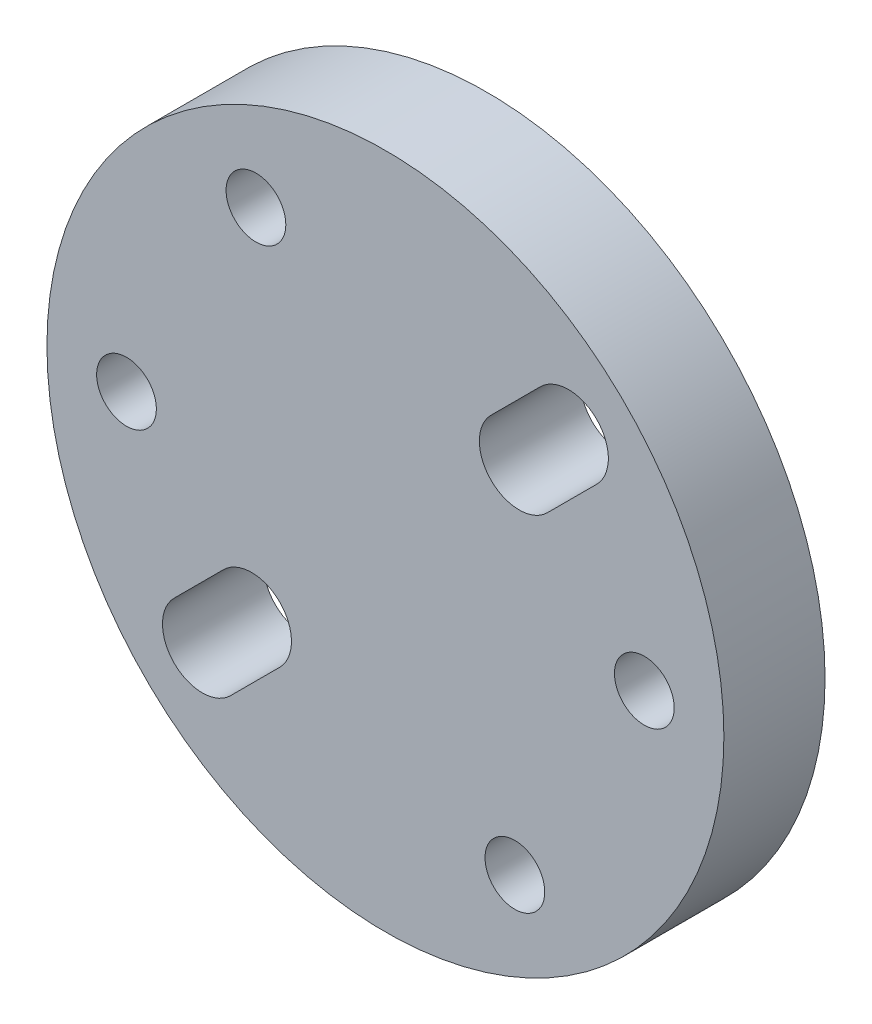
from build123d import *

# Parameters (mm, degrees)
SKETCH1_R           = 16.995
SKETCH1_R_2         = 1.5
BOSS_EXTRUDE1_DEPTH = 5.08
CUT_EXTRUDE2_DEPTH  = 10


with BuildPart() as part:
    # Sketch1 → Boss-Extrude1 (new body)
    with BuildSketch(Plane.XY):
        Circle(SKETCH1_R)
        with Locations((-6.5, -11.258330249)):
            Circle(SKETCH1_R_2, mode=Mode.SUBTRACT)
        with Locations((6.5, -11.258330249)):
            Circle(SKETCH1_R_2, mode=Mode.SUBTRACT)
        with Locations((13, 0)):
            Circle(SKETCH1_R_2, mode=Mode.SUBTRACT)
        with Locations((6.5, 11.258330249)):
            Circle(SKETCH1_R_2, mode=Mode.SUBTRACT)
        with Locations((-6.5, 11.258330249)):
            Circle(SKETCH1_R_2, mode=Mode.SUBTRACT)
        with Locations((-13, 0)):
            Circle(SKETCH1_R_2, mode=Mode.SUBTRACT)
        with Locations((6.5, 11.258330249)):
            Circle(SKETCH1_R_2)
        with Locations((-6.5, -11.258330249)):
            Circle(SKETCH1_R_2)
    extrude(amount=BOSS_EXTRUDE1_DEPTH)

    # Sketch2 → Cut-Extrude2 (cut)
    with BuildSketch(Plane.XY.offset(5.08)):
        with BuildLine():
            ThreePointArc((-5.303300859, -8.131727984), (-5.303300859, -5.303300859), (-8.131727984, -5.303300859))
            Line((-8.131727984, -5.303300859), (-10.606601718, -7.778174593))
            ThreePointArc((-10.606601718, -7.778174593), (-10.606601718, -10.606601718), (-7.778174593, -10.606601718))
            Line((-7.778174593, -10.606601718), (-5.303300859, -8.131727984))
        make_face()
        with BuildLine():
            ThreePointArc((10.606601718, 7.778174593), (10.606601718, 10.606601718), (7.778174593, 10.606601718))
            Line((7.778174593, 10.606601718), (5.303300859, 8.131727984))
            ThreePointArc((5.303300859, 8.131727984), (5.303300859, 5.303300859), (8.131727984, 5.303300859))
            Line((8.131727984, 5.303300859), (10.606601718, 7.778174593))
        make_face()
    extrude(amount=-CUT_EXTRUDE2_DEPTH, mode=Mode.SUBTRACT)


solid = part.part
